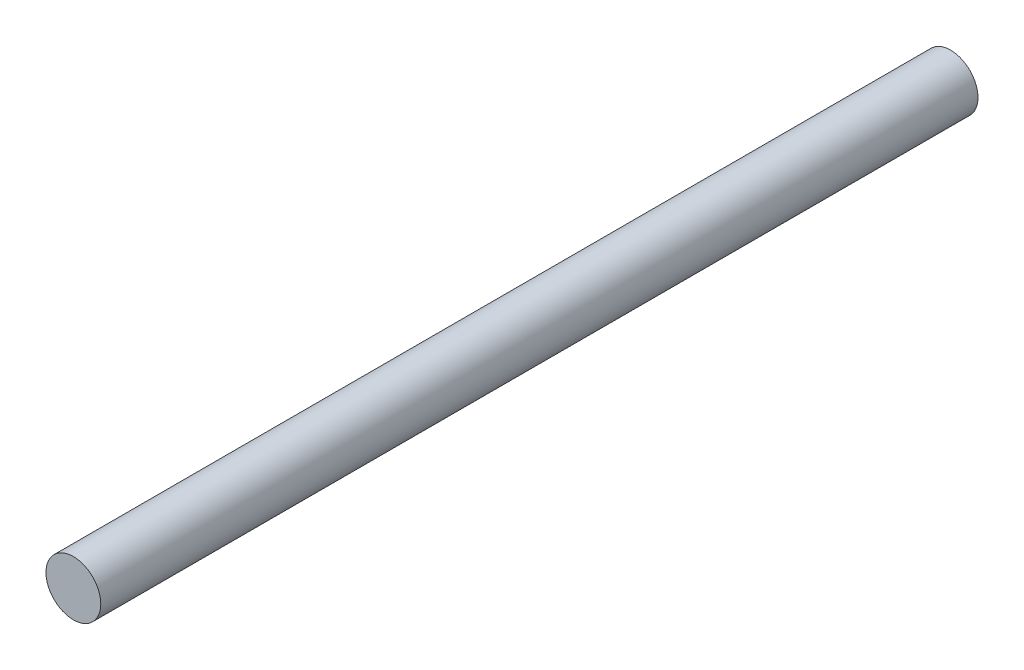
from build123d import *

# Parameters (mm, degrees)
SKETCH1_R           = 2.5
BOSS_EXTRUDE1_DEPTH = 80


with BuildPart() as part:
    # Sketch1 → Boss-Extrude1 (new body)
    with BuildSketch(Plane.XY):
        Circle(SKETCH1_R)
    extrude(amount=BOSS_EXTRUDE1_DEPTH)


solid = part.part
